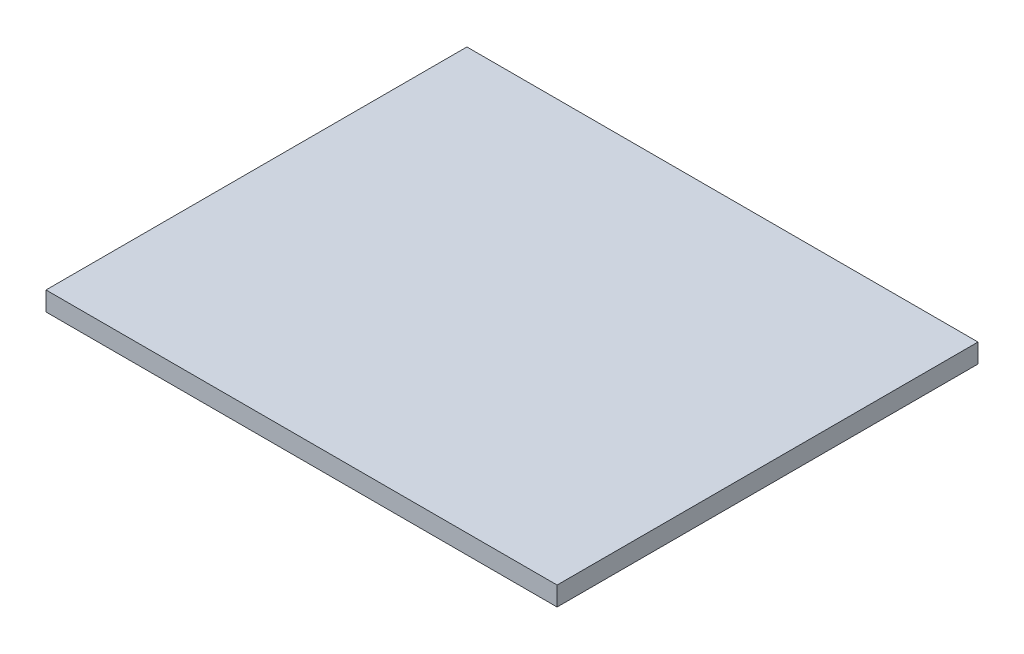
from build123d import *

# Parameters (mm, degrees)
SKETCH1_W           = 85
SKETCH1_H           = 70
BOSS_EXTRUDE1_DEPTH = 3.175


with BuildPart() as part:
    # Sketch1 → Boss-Extrude1 (new body)
    with BuildSketch(Plane(origin=(0, 0, 0), x_dir=(1, 0, 0), z_dir=(0, 1, 0))):
        with Locations((42.5, 35)):
            Rectangle(SKETCH1_W, SKETCH1_H)
    extrude(amount=BOSS_EXTRUDE1_DEPTH)


solid = part.part
